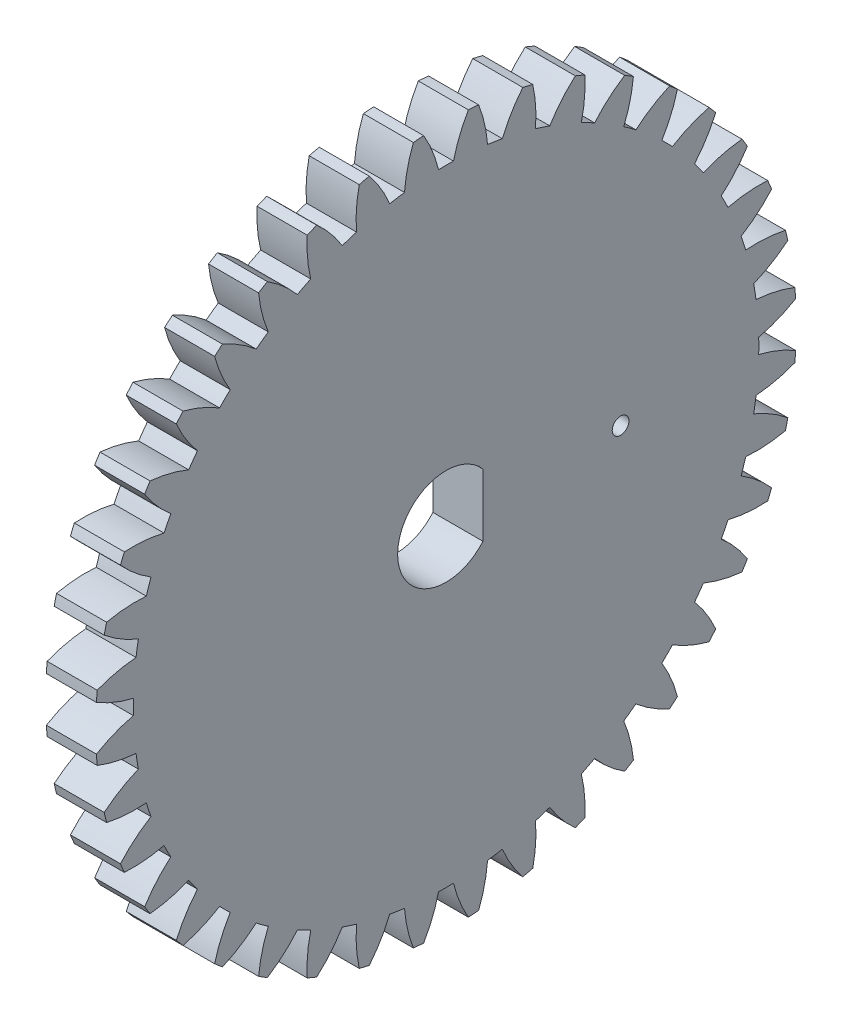
from build123d import *

# Parameters (mm, degrees)
BASPROSKE_W        = 3
BASPROSKE_H        = 21
TOOTHCUT_DEPTH     = 30.849623113
TEETHCUTS_COUNT    = 40
TEETHCUTS_ANGLE    = 351
BORSKE_R           = 1.5
BORE_DEPTH         = 50.0007112
SKETCH1_R          = 0.5
CUT_EXTRUDE1_DEPTH = 30.78938648


with BuildPart() as part:
    # BasProSke → Base-Revolve (revolve)
    with BuildSketch(Plane(origin=(0, 0, 0), x_dir=(1, 0, 0), z_dir=(0, 1, 0)), mode=Mode.PRIVATE) as base_revolve_sk:
        with Locations((1.5, 10.5)):
            Rectangle(BASPROSKE_W, BASPROSKE_H)
    revolve(base_revolve_sk.sketch.rotate(Axis((-10, 0, 0), (1, 0, 0)), 180), axis=Axis((-10, 0, 0), (1, 0, 0)))

    # TooCutSke → ToothCut (cut, through all)
    with BuildSketch(Plane(origin=(0, 0, 0), x_dir=(0, 0, -1), z_dir=(1, 0, 0))):
        with BuildLine():
            ThreePointArc((0.448673268, 18.74363074), (0, 18.749), (-0.448673268, 18.74363074))
            ThreePointArc((-0.448673268, 18.74363074), (-0.816786816, 19.89705013), (-1.354745081, 20.981708961))
            ThreePointArc((-1.354745081, 20.981708961), (0, 21.0254), (1.354745081, 20.981708961))
            ThreePointArc((1.354745081, 20.981708961), (0.816786816, 19.89705013), (0.448673268, 18.74363074))
        make_face()
    toothcut = extrude(amount=TOOTHCUT_DEPTH, mode=Mode.SUBTRACT)

    # TeethCuts: ToothCut ×40 about axis
    teethcuts_axis = Axis((-10, 0, 0), (1, 0, 0))
    for i in range(1, TEETHCUTS_COUNT):
        add(toothcut.rotate(teethcuts_axis, i * TEETHCUTS_ANGLE / (TEETHCUTS_COUNT - 1)), mode=Mode.SUBTRACT)

    # BorSke → Bore (cut, symmetric)
    with BuildSketch(Plane(origin=(0, 0, 0), x_dir=(0, 0, -1), z_dir=(1, 0, 0))):
        with Locations(Location((0, 0, 0), (0, 0, 180))):
            Circle(BORSKE_R)
    extrude(amount=BORE_DEPTH, both=True, mode=Mode.SUBTRACT)

    # Sketch1 → Cut-Extrude1 (cut, through all)
    with BuildSketch(Plane(origin=(3, 0, 0), x_dir=(0, 0, -1), z_dir=(1, 0, 0))):
        with Locations((10.463187158, 0)):
            Circle(SKETCH1_R)
        with BuildLine():
            Line((2.212323439, -1.875), (2.212323439, 1.875))
            ThreePointArc((2.212323439, 1.875), (-2.9, 0), (2.212323439, -1.875))
        make_face()
    extrude(amount=-CUT_EXTRUDE1_DEPTH, mode=Mode.SUBTRACT)


solid = part.part
